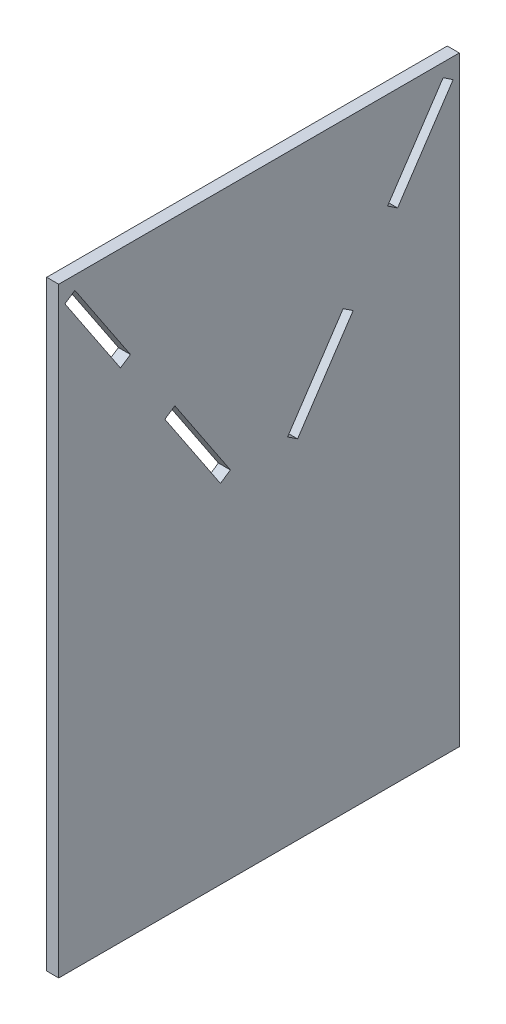
from build123d import *

# Parameters (mm, degrees)
SKETCH_1_W      = 200
SKETCH_1_H      = 300
EXTRUDE_1_DEPTH = 6


with BuildPart() as part:
    # Эскиз1 → Бобышка-Вытянуть1 (new body)
    with BuildSketch(Plane(origin=(0, 0, 0), x_dir=(0, 0, -1), z_dir=(1, 0, 0))):
        Rectangle(SKETCH_1_W, SKETCH_1_H)
        Polygon((-91.932327425, 143.306818051), (-96.924629192, 139.978616874), (-69.18961938, 98.376102157), (-64.197317614, 101.704303335), align=None, mode=Mode.SUBTRACT)
        Polygon((-19.26660172, 23.491575667), (-14.274299954, 26.819776844), (-42.009309765, 68.422291561), (-47.001611531, 65.094090384), align=None, mode=Mode.SUBTRACT)
        Polygon((19.26660172, 23.491575667), (47.001611531, 65.094090384), (42.009309765, 68.422291561), (14.274299954, 26.819776844), align=None, mode=Mode.SUBTRACT)
        Polygon((96.924629192, 139.978616874), (69.18961938, 98.376102157), (64.197317614, 101.704303335), (91.932327425, 143.306818051), align=None, mode=Mode.SUBTRACT)
    extrude(amount=EXTRUDE_1_DEPTH)


solid = part.part
